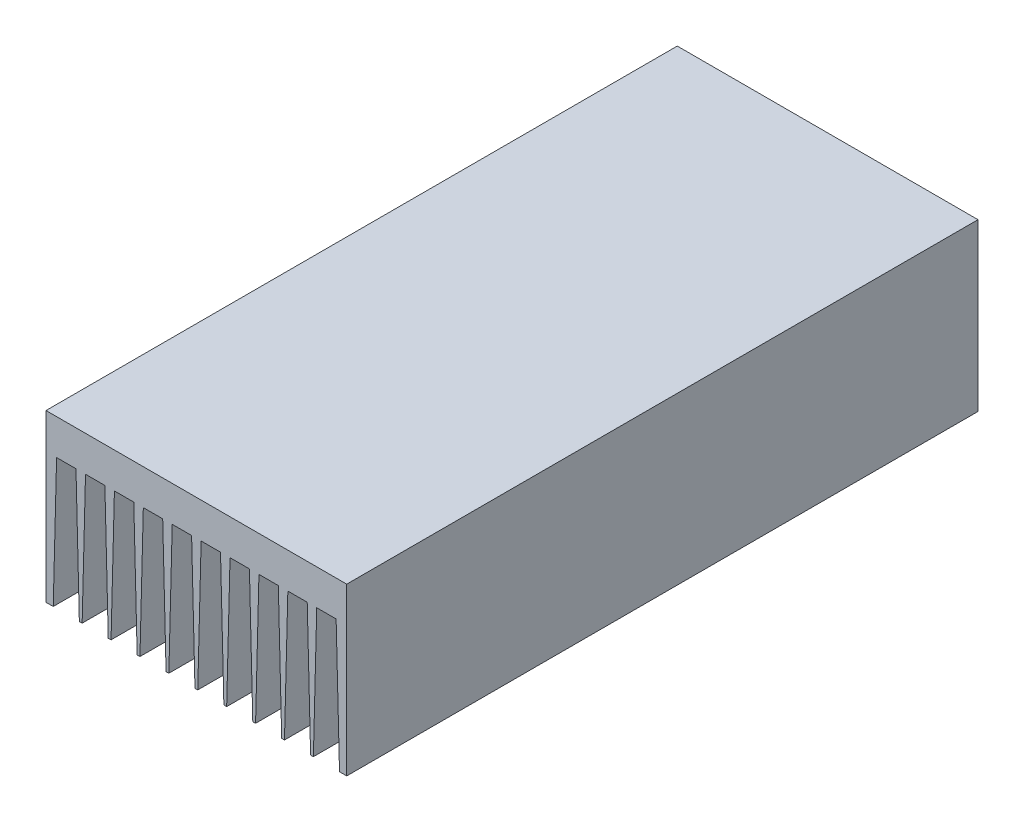
from build123d import *

# Parameters (mm, degrees)
RESSALTO_EXTRUS_O1_DEPTH = 285


with BuildPart() as part:
    # Esboço1 → Ressalto-extrusão1 (new body)
    with BuildSketch(Plane.XY):
        Polygon((0, 75), (135.77, 75), (135.77, 0), (132.504208406, 0), (130.985, 59), (122.235, 59), (120.715791594, 0), (119.454208406, 0), (117.935, 59), (109.185, 59), (107.665791594, 0), (106.404208406, 0), (104.885, 59), (96.135, 59), (94.615791594, 0), (93.354208406, 0), (91.835, 59), (83.085, 59), (81.565791594, 0), (80.304208406, 0), (78.785, 59), (70.035, 59), (68.515791594, 0), (67.254208406, 0), (65.735, 59), (56.985, 59), (55.465791594, 0), (54.204208406, 0), (52.685, 59), (43.935, 59), (42.415791594, 0), (41.154208406, 0), (39.635, 59), (30.885, 59), (29.365791594, 0), (28.104208406, 0), (26.585, 59), (17.835, 59), (16.315791594, 0), (15.054208406, 0), (13.535, 59), (4.785, 59), (3.265791594, 0), (0, 0), align=None)
    extrude(amount=RESSALTO_EXTRUS_O1_DEPTH)


solid = part.part
